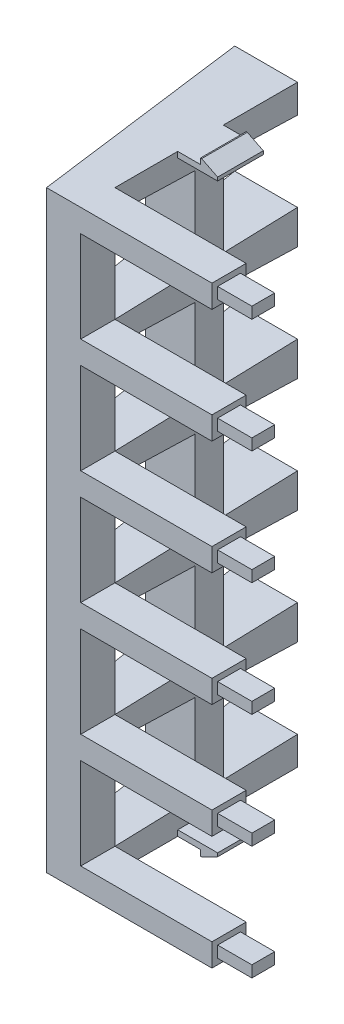
from build123d import *

# Parameters (mm, degrees)
EXTRUDE_1_DEPTH        = 52
SKETCH_2_W             = 14.5
SKETCH_2_H             = 8
CUT_EXTRUDE_1_DEPTH    = 4
PATTERN_LINEAR_1_COUNT = 5
PATTERN_LINEAR_1_PITCH = 10
CUT_EXTRUDE_2_DEPTH    = 6.5
PATTERN_LINEAR_2_COUNT = 5
PATTERN_LINEAR_2_PITCH = 10
SKETCH_5_W             = 3
SKETCH_5_H             = 2
SKETCH_5_W_2           = 2
SKETCH_5_H_2           = 1
CUT_EXTRUDE_3_DEPTH    = 3
PATTERN_LINEAR_3_COUNT = 6
PATTERN_LINEAR_3_PITCH = 10
EXTRUDE_2_DEPTH        = 3.5
SKETCH_8_W             = 2
SKETCH_8_H             = 0.5
CUT_EXTRUDE_4_DEPTH    = 5


with BuildPart() as part:
    # 草图1 → 凸台-拉伸1 (new body)
    with BuildSketch(Plane(origin=(0, 0, 0), x_dir=(1, 0, 0), z_dir=(0, 1, 0))):
        Polygon((0, 19), (-2.5, 19), (0, 0), (17.5, 0), (17.5, 3), (3, 3), (3, 19), align=None)
    extrude(amount=EXTRUDE_1_DEPTH)

    # 草图2 → 切除-拉伸1 (cut, through all)
    with BuildSketch(Plane(origin=(0, 0, -3), x_dir=(-1, 0, 0), z_dir=(0, 0, -1))):
        with Locations((-10.25, 46)):
            Rectangle(SKETCH_2_W, SKETCH_2_H)
    cut_extrude_1 = extrude(amount=-CUT_EXTRUDE_1_DEPTH, mode=Mode.SUBTRACT)

    # 阵列(线性)1: 切除-拉伸1 ×5
    with Locations(*[(0, -i * PATTERN_LINEAR_1_PITCH, 0) for i in range(1, PATTERN_LINEAR_1_COUNT)]):
        add(cut_extrude_1, mode=Mode.SUBTRACT)

    # 草图4 → 切除-拉伸2 (cut, through all)
    with BuildSketch(Plane(origin=(3, 0, 0), x_dir=(0, 0, -1), z_dir=(1, 0, 0))):
        Polygon((3, 50), (3, 42), (10, 42.21875), (10, 49.78125), align=None)
        Polygon((19, 49.5), (19, 42.5), (12.5, 42.296875), (12.5, 49.703125), align=None)
    cut_extrude_2 = extrude(amount=-CUT_EXTRUDE_2_DEPTH, mode=Mode.SUBTRACT)

    # 阵列(线性)2: 切除-拉伸2 ×5
    with Locations(*[(0, -i * PATTERN_LINEAR_2_PITCH, 0) for i in range(1, PATTERN_LINEAR_2_COUNT)]):
        add(cut_extrude_2, mode=Mode.SUBTRACT)

    # 草图5 → 切除-拉伸3 (cut)
    with BuildSketch(Plane(origin=(17.5, 0, 0), x_dir=(0, 0, -1), z_dir=(1, 0, 0))):
        with Locations((1.5, 51)):
            Rectangle(SKETCH_5_W, SKETCH_5_H)
        with Locations((1.5, 51)):
            Rectangle(SKETCH_5_W_2, SKETCH_5_H_2, mode=Mode.SUBTRACT)
    cut_extrude_3 = extrude(amount=-CUT_EXTRUDE_3_DEPTH, mode=Mode.SUBTRACT)

    # 阵列(线性)3: 切除-拉伸3 ×6
    with Locations(*[(0, -i * PATTERN_LINEAR_3_PITCH, 0) for i in range(1, PATTERN_LINEAR_3_COUNT)]):
        add(cut_extrude_3, mode=Mode.SUBTRACT)

    # 草图6 → 凸台-拉伸2 (add)
    with BuildSketch(Plane(origin=(3, 0, 0), x_dir=(0, 0, -1), z_dir=(1, 0, 0))):
        Polygon((8.5, 0), (8.5, 0.5), (12.5, 0.5), (12.5, 0), (12.5, -0.5), (8.5, -0.5), align=None)
    extrude_2 = extrude(amount=EXTRUDE_2_DEPTH)

    # 草图8 → 切除-拉伸4 (cut)
    with BuildSketch(Plane.XY.offset(-8.5)):
        with Locations((4, -0.25)):
            Rectangle(SKETCH_8_W, SKETCH_8_H)
        Polygon((6.5, -0.5), (5.1, -0.5), (6.5, 0.2), align=None)
    cut_extrude_4 = extrude(amount=-CUT_EXTRUDE_4_DEPTH, mode=Mode.SUBTRACT)

    # 镜向1: 凸台-拉伸2, 切除-拉伸4 across plane
    add(extrude_2.mirror(Plane.ZX.offset(26)))
    add(cut_extrude_4.mirror(Plane.ZX.offset(26)), mode=Mode.SUBTRACT)


solid = part.part
